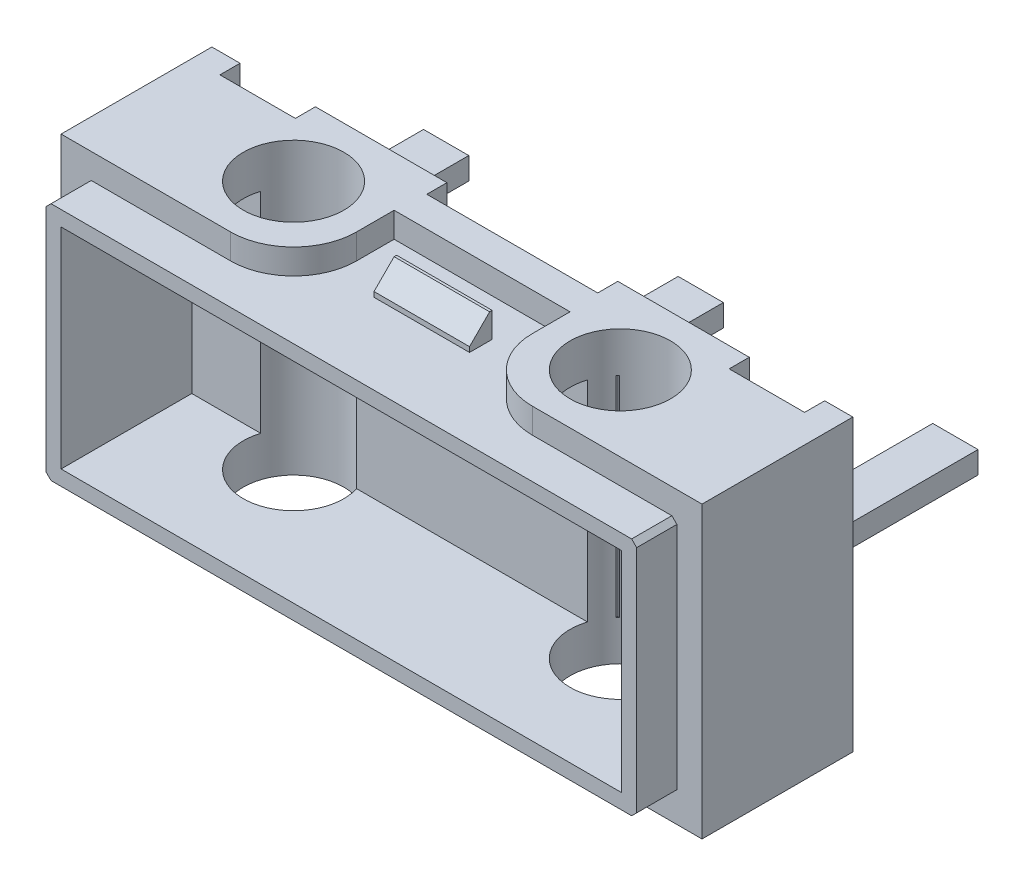
from build123d import *

# Parameters (mm, degrees)
ESQUISSE1_W                  = 12.75
ESQUISSE1_H                  = 5.77
BASE_EXTRUSION_DEPTH         = 3
ESQUISSE2_W                  = 1.5
ESQUISSE2_H                  = 0.4
ESQUISSE2_W_2                = 3.4
ENL_V_MAT_EXTRU_1_DEPTH      = 3.885
ENL_V_MAT_EXTRU_1_DEPTH_BACK = 3.885
COQUE1_T                     = -0.8
ESQUISSE3_W                  = 0.9
ESQUISSE3_H                  = 0.44
BOSS_EXTRU_1_DEPTH           = 3.75
ESQUISSE4_W                  = 11.75
ESQUISSE4_H                  = 4.77
ESQUISSE4_W_2                = 11.15
ESQUISSE4_H_2                = 4.17
BOSS_EXTRU_2_DEPTH           = 0.8
ENL_V_MAT_EXTRU_2_DEPTH      = 0.5
SYM_TRIE2_COPY_1_DEPTH       = 0.5
CHANFREIN1_SIZE              = 0.1
ESQUISSE6_W                  = 1.9
ESQUISSE6_H                  = 0.45
BOSS_EXTRU_3_DEPTH           = 0.5
CHANFREIN2_SIZE              = 0.4
CHANFREIN2_OF_SYM_TRIE3_SIZE = 0.4
ESQUISSE7_R                  = 1
ENL_V_MAT_EXTRU_3_DEPTH      = 3.885
ENL_V_MAT_EXTRU_3_DEPTH_BACK = 3.885


with BuildPart() as part:
    # Esquisse1 → Base-Extrusion (new body)
    with BuildSketch(Plane.XY):
        Rectangle(ESQUISSE1_W, ESQUISSE1_H)
    extrude(amount=-BASE_EXTRUSION_DEPTH)

    # Esquisse2 → Enlèv. mat.-Extru.1 (cut, two sides)
    with BuildSketch(Plane(origin=(0, 0, 0), x_dir=(1, 0, 0), z_dir=(0, 1, 0))) as enl_v_mat_extru_1_sk:
        with Locations((-5.065, 2.8)):
            Rectangle(ESQUISSE2_W, ESQUISSE2_H)
        with Locations((5.065, 2.8)):
            Rectangle(ESQUISSE2_W, ESQUISSE2_H)
        with Locations((0, 2.8)):
            Rectangle(ESQUISSE2_W_2, ESQUISSE2_H)
    extrude(amount=ENL_V_MAT_EXTRU_1_DEPTH, mode=Mode.SUBTRACT)
    extrude(enl_v_mat_extru_1_sk.sketch, amount=-ENL_V_MAT_EXTRU_1_DEPTH_BACK, mode=Mode.SUBTRACT)

    # Coque1
    coque1_openings = [part.faces().sort_by_distance(p)[0] for p in [
        (0, 0, 0),
    ]]
    offset(amount=COQUE1_T, openings=coque1_openings, kind=Kind.INTERSECTION)

    # Esquisse3 → Boss.-Extru.1 (add)
    with BuildSketch(Plane(origin=(0, 0, -2.6), x_dir=(-1, 0, 0), z_dir=(0, 0, -1))):
        with Locations((-5.065, 0)):
            Rectangle(ESQUISSE3_W, ESQUISSE3_H)
        with Locations((5.065, 0)):
            Rectangle(ESQUISSE3_W, ESQUISSE3_H)
        Rectangle(ESQUISSE3_W, ESQUISSE3_H)
    extrude(amount=BOSS_EXTRU_1_DEPTH)

    # Esquisse4 → Boss.-Extru.2 (add)
    with BuildSketch(Plane.XY):
        Rectangle(ESQUISSE4_W, ESQUISSE4_H)
        Rectangle(ESQUISSE4_W_2, ESQUISSE4_H_2, mode=Mode.SUBTRACT)
    extrude(amount=BOSS_EXTRU_2_DEPTH)

    # Esquisse5 → Enlèv. mat.-Extru.2 (cut)
    with BuildSketch(Plane(origin=(0, 2.885, 0), x_dir=(1, 0, 0), z_dir=(0, 1, 0))):
        with BuildLine():
            Line((3, 0), (0, 0))
            Line((0, 0), (0, 2))
            Line((0, 2), (1.75, 2))
            Line((1.75, 2), (1.75, 1.25))
            ThreePointArc((1.75, 1.25), (2.116116524, 0.366116524), (3, 0))
        make_face()
    enl_v_mat_extru_2 = extrude(amount=-ENL_V_MAT_EXTRU_2_DEPTH, mode=Mode.SUBTRACT)

    # Symétrie1: Enlèv. mat.-Extru.2 across plane
    add(enl_v_mat_extru_2.mirror(Plane(origin=(0, 0, 0), x_dir=(0, 0, 1), z_dir=(1, 0, 0))), mode=Mode.SUBTRACT)

    # Symétrie2: Enlèv. mat.-Extru.2 across plane
    add(enl_v_mat_extru_2.mirror(Plane.ZX), mode=Mode.SUBTRACT)

    # Symétrie2 copy 1 sketch → Symétrie2 copy 1 (cut)
    with BuildSketch(Plane(origin=(0, -2.885, 0), x_dir=(-1, 0, 0), z_dir=(0, -1, 0))):
        with BuildLine():
            Line((3, 0), (0, 0))
            Line((0, 0), (0, 2))
            Line((0, 2), (1.75, 2))
            Line((1.75, 2), (1.75, 1.25))
            ThreePointArc((1.75, 1.25), (2.116116524, 0.366116524), (3, 0))
        make_face()
    extrude(amount=-SYM_TRIE2_COPY_1_DEPTH, mode=Mode.SUBTRACT)

    # Chanfrein1
    chanfrein1_edges = [part.edges().sort_by_distance(p)[0] for p in [
        (5.875, -2.385, 0.4),
        (5.875, 2.385, 0.4),
        (-5.875, 2.385, 0.4),
        (-5.875, -2.385, 0.4),
    ]]
    chamfer(chanfrein1_edges, length=CHANFREIN1_SIZE)

    # Esquisse6 → Boss.-Extru.3 (add)
    with BuildSketch(Plane(origin=(0, 2.385, 0), x_dir=(-1, 0, 0), z_dir=(0, 1, 0))):
        with Locations((0, -1.025)):
            Rectangle(ESQUISSE6_W, ESQUISSE6_H)
    boss_extru_3 = extrude(amount=BOSS_EXTRU_3_DEPTH)

    # Chanfrein2
    chanfrein2_edges = [part.edges().sort_by_distance(p)[0] for p in [
        (0, 2.885, -0.8),
    ]]
    chamfer(chanfrein2_edges, length=CHANFREIN2_SIZE)

    # Symétrie3: Boss.-Extru.3 across plane
    add(boss_extru_3.mirror(Plane.ZX))

    # Chanfrein2 of Symétrie3
    chanfrein2_of_sym_trie3_edges = [part.edges().sort_by_distance(p)[0] for p in [
        (0, -2.885, -0.8),
    ]]
    chamfer(chanfrein2_of_sym_trie3_edges, length=CHANFREIN2_OF_SYM_TRIE3_SIZE)

    # Esquisse7 → Enlèv. mat.-Extru.3 (cut, two sides)
    with BuildSketch(Plane(origin=(0, 0, 0), x_dir=(1, 0, 0), z_dir=(0, 1, 0))) as enl_v_mat_extru_3_sk:
        with Locations((3.25, 1.5)):
            Circle(ESQUISSE7_R)
        with Locations((-3.25, 1.5)):
            Circle(ESQUISSE7_R)
    extrude(amount=ENL_V_MAT_EXTRU_3_DEPTH, mode=Mode.SUBTRACT)
    extrude(enl_v_mat_extru_3_sk.sketch, amount=-ENL_V_MAT_EXTRU_3_DEPTH_BACK, mode=Mode.SUBTRACT)


solid = part.part
